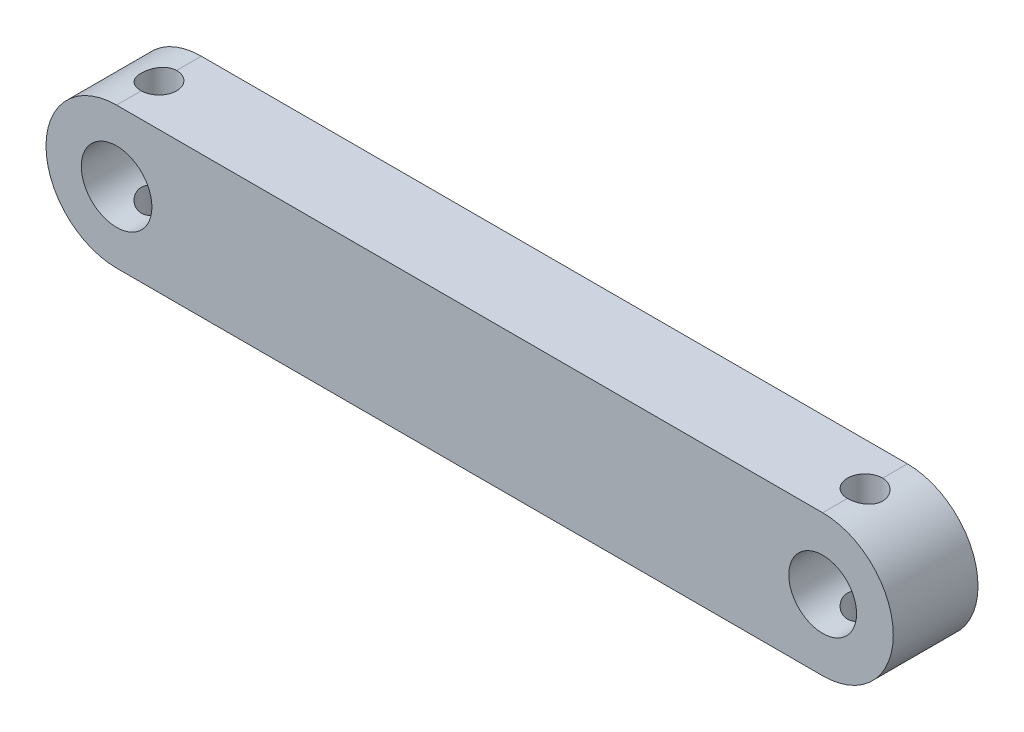
from build123d import *

# Parameters (mm, degrees)
SKETCH1_R               = 2.4
SKETCH1_R_2             = 2.5
BOSS_EXTRUDE1_DEPTH     = 6
SKETCH2_R               = 1.25
CUT_EXTRUDE1_DEPTH      = 1
CUT_EXTRUDE1_DEPTH_BACK = 11


with BuildPart() as part:
    # Sketch1 → Boss-Extrude1 (new body)
    with BuildSketch(Plane.XY):
        with BuildLine():
            Line((-39.716981132, 22.452830189), (10.283018868, 22.452830189))
            ThreePointArc((10.283018868, 22.452830189), (15.283018868, 17.452830189), (10.283018868, 12.452830189))
            Line((10.283018868, 12.452830189), (-39.716981132, 12.452830189))
            ThreePointArc((-39.716981132, 12.452830189), (-44.716981132, 17.452830189), (-39.716981132, 22.452830189))
        make_face()
        with Locations((10.283018868, 17.452830189)):
            Circle(SKETCH1_R, mode=Mode.SUBTRACT)
        with Locations((-39.716981132, 17.452830189)):
            Circle(SKETCH1_R_2, mode=Mode.SUBTRACT)
    extrude(amount=BOSS_EXTRUDE1_DEPTH)

    # Sketch2 → Cut-Extrude1 (cut, two sides)
    with BuildSketch(Plane(origin=(0, 22.452830189, 0), x_dir=(1, 0, 0), z_dir=(0, 1, 0))) as cut_extrude1_sk:
        with Locations((-39.716981132, -3)):
            Circle(SKETCH2_R)
        with Locations((10.283018868, -3)):
            Circle(SKETCH2_R)
    extrude(amount=CUT_EXTRUDE1_DEPTH, mode=Mode.SUBTRACT)
    extrude(cut_extrude1_sk.sketch, amount=-CUT_EXTRUDE1_DEPTH_BACK, mode=Mode.SUBTRACT)


solid = part.part
